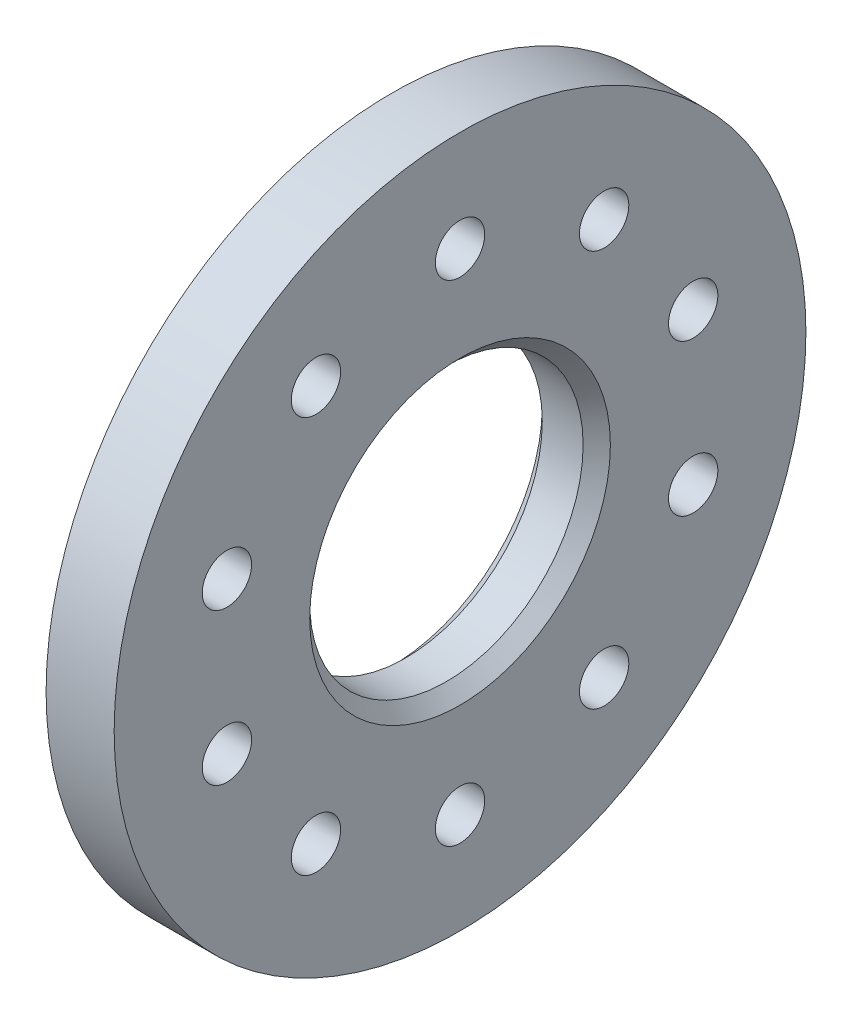
from build123d import *

# Parameters (mm, degrees)
SKETCH1_R           = 80.645
BOSS_EXTRUDE1_DEPTH = 7.9375
SKETCH3_R           = 31.877
CUT_EXTRUDE1_DEPTH  = 16.875
CHAMFER1_SIZE       = 3.175
SKETCH5_R           = 5.7546875
CUT_EXTRUDE2_DEPTH  = 16.875
CIRPATTERN1_COUNT   = 5
SKETCH6_R           = 5.7546875
CUT_EXTRUDE3_DEPTH  = 16.875
CIRPATTERN2_COUNT   = 5


with BuildPart() as part:
    # Sketch1 → Boss-Extrude1 (new body, symmetric)
    with BuildSketch(Plane(origin=(0, 0, 0), x_dir=(0, 0, -1), z_dir=(1, 0, 0))):
        Circle(SKETCH1_R)
    extrude(amount=BOSS_EXTRUDE1_DEPTH, both=True)

    # Sketch3 → Cut-Extrude1 (cut, through all)
    with BuildSketch(Plane(origin=(7.9375, 0, 0), x_dir=(0, 0, -1), z_dir=(1, 0, 0))):
        Circle(SKETCH3_R)
    extrude(amount=-CUT_EXTRUDE1_DEPTH, mode=Mode.SUBTRACT)

    # Chamfer1
    chamfer1_edges = [part.edges().sort_by_distance(p)[0] for p in [
        (-7.9375, 0, 31.877),
        (7.9375, 0, 31.877),
    ]]
    chamfer(chamfer1_edges, length=CHAMFER1_SIZE)

    # Sketch5 → Cut-Extrude2 (cut, through all)
    with BuildSketch(Plane(origin=(7.9375, 0, 0), x_dir=(0, 0, -1), z_dir=(1, 0, 0))):
        with Locations((0, 57.15)):
            Circle(SKETCH5_R)
    cut_extrude2 = extrude(amount=-CUT_EXTRUDE2_DEPTH, mode=Mode.SUBTRACT)

    # CirPattern1: Cut-Extrude2 ×5 about axis
    cirpattern1_axis = Axis((0, 0, 0), (1, 0, 0))
    for i in range(1, CIRPATTERN1_COUNT):
        add(cut_extrude2.rotate(cirpattern1_axis, i * 360 / CIRPATTERN1_COUNT), mode=Mode.SUBTRACT)

    # Sketch6 → Cut-Extrude3 (cut, through all)
    with BuildSketch(Plane(origin=(7.9375, 0, 0), x_dir=(0, 0, -1), z_dir=(1, 0, 0))):
        with Locations((0, -57.15)):
            Circle(SKETCH6_R)
    cut_extrude3 = extrude(amount=-CUT_EXTRUDE3_DEPTH, mode=Mode.SUBTRACT)

    # CirPattern2: Cut-Extrude3 ×5 about axis
    cirpattern2_axis = Axis((0, 0, 0), (1, 0, 0))
    for i in range(1, CIRPATTERN2_COUNT):
        add(cut_extrude3.rotate(cirpattern2_axis, i * 360 / CIRPATTERN2_COUNT), mode=Mode.SUBTRACT)


solid = part.part
